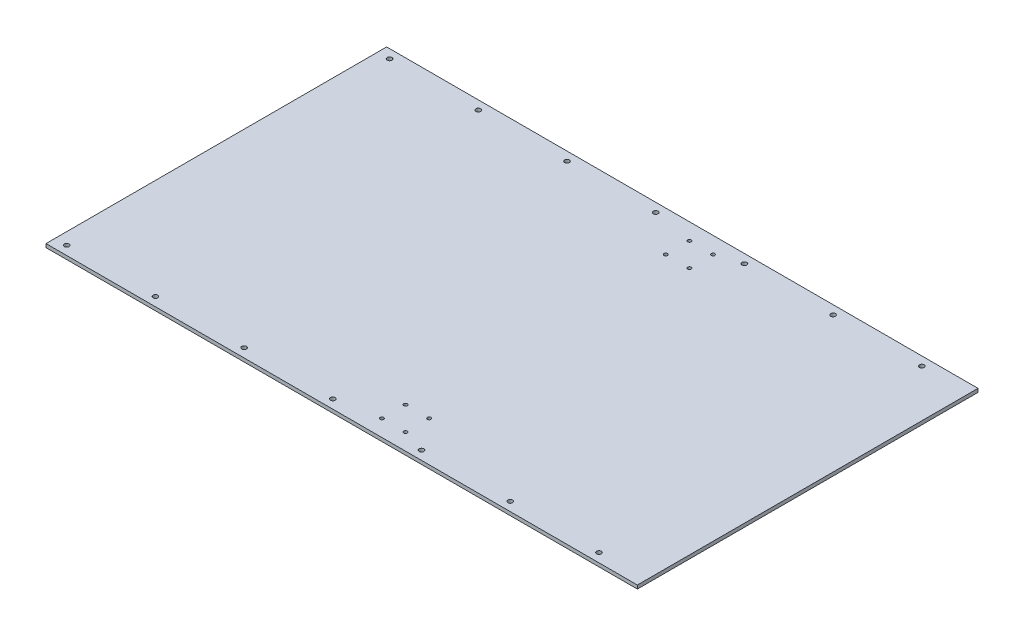
from build123d import *

# Parameters (mm, degrees)
SKETCH1_W           = 500
SKETCH1_H           = 288
BOSS_EXTRUDE1_DEPTH = 3
SKETCH2_R           = 2
CUT_EXTRUDE1_DEPTH  = 10
SKETCH3_R           = 1.5
CUT_EXTRUDE2_DEPTH  = 10


with BuildPart() as part:
    # Sketch1 → Boss-Extrude1 (new body)
    with BuildSketch(Plane(origin=(0, 0, 0), x_dir=(1, 0, 0), z_dir=(0, 1, 0))):
        Rectangle(SKETCH1_W, SKETCH1_H)
    extrude(amount=BOSS_EXTRUDE1_DEPTH)

    # Sketch2 → Cut-Extrude1 (cut)
    with BuildSketch(Plane(origin=(0, 3, 0), x_dir=(1, 0, 0), z_dir=(0, 1, 0))):
        with Locations((-240, 136.5)):
            Circle(SKETCH2_R)
        with Locations((-165, 136.5)):
            Circle(SKETCH2_R)
        with Locations((-90, 136.5)):
            Circle(SKETCH2_R)
        with Locations((-15, 136.5)):
            Circle(SKETCH2_R)
        with Locations((60, 136.5)):
            Circle(SKETCH2_R)
        with Locations((135, 136.5)):
            Circle(SKETCH2_R)
        with Locations((135, -136.5)):
            Circle(SKETCH2_R)
        with Locations((60, -136.5)):
            Circle(SKETCH2_R)
        with Locations((-15, -136.5)):
            Circle(SKETCH2_R)
        with Locations((-90, -136.5)):
            Circle(SKETCH2_R)
        with Locations((-165, -136.5)):
            Circle(SKETCH2_R)
        with Locations((-240, -136.5)):
            Circle(SKETCH2_R)
        with Locations((210, 136.5)):
            Circle(SKETCH2_R)
        with Locations((210, -136.5)):
            Circle(SKETCH2_R)
    extrude(amount=-CUT_EXTRUDE1_DEPTH, mode=Mode.SUBTRACT)

    # Sketch3 → Cut-Extrude2 (cut)
    with BuildSketch(Plane(origin=(0, 0, 0), x_dir=(-1, 0, 0), z_dir=(0, -1, 0))):
        with Locations((-20, -110)):
            Circle(SKETCH3_R)
        with Locations((-40, -110)):
            Circle(SKETCH3_R)
        with Locations((-20, 110)):
            Circle(SKETCH3_R)
        with Locations((-40, 110)):
            Circle(SKETCH3_R)
        with Locations((-20, 130)):
            Circle(SKETCH3_R)
        with Locations((-40, 130)):
            Circle(SKETCH3_R)
        with Locations((-20, -130)):
            Circle(SKETCH3_R)
        with Locations((-40, -130)):
            Circle(SKETCH3_R)
    extrude(amount=-CUT_EXTRUDE2_DEPTH, mode=Mode.SUBTRACT)


solid = part.part
